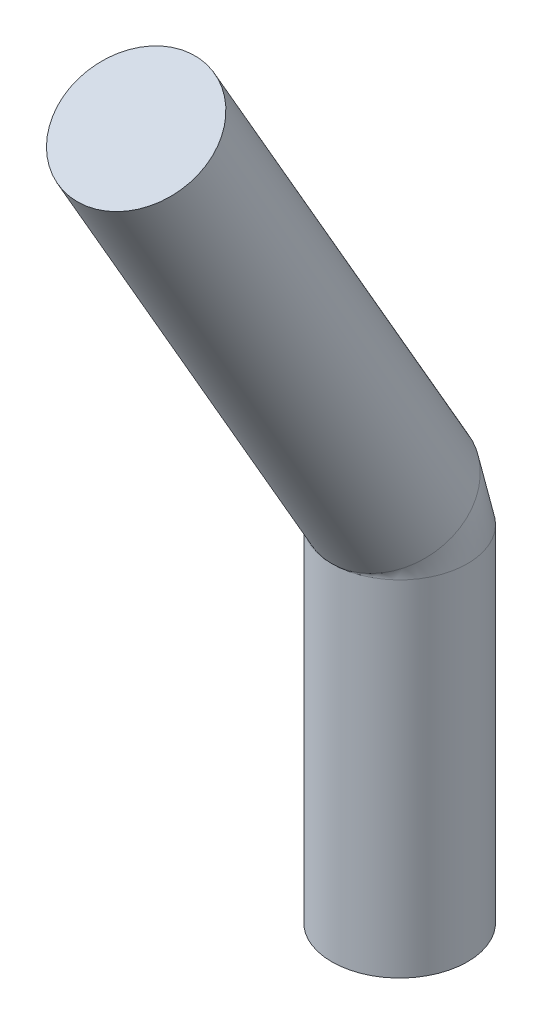
from build123d import *

# Parameters (mm, degrees)
SKETCH23_R          = 0.6
SKETCH25_R          = 0.6
BOSS_EXTRUDE2_DEPTH = 2.55


with BuildPart() as part:
    # Sweep4: sweep along a path in Sketch24
    with BuildLine(Plane(origin=(0, 0, 0), x_dir=(0, 0, -1), z_dir=(1, 0, 0))) as sweep4_path:
        Line((0, 0), (0, 0.5))
        ThreePointArc((0, 0.5), (-0.020444504, 0.655291427), (-0.080384758, 0.8))
        Line((-0.080384758, 0.8), (-2.330384758, 4.697114317))
    # Sketch23 → Sweep4 (sweep)
    with BuildSketch(Plane(origin=(0, 0, 0), x_dir=(1, 0, 0), z_dir=(0, 1, 0))):
        Circle(SKETCH23_R)
    sweep(path=sweep4_path.line)

    # Sketch25 → Boss-Extrude2 (add)
    with BuildSketch(Plane(origin=(0, 0, 0), x_dir=(-1, 0, 0), z_dir=(0, -1, 0))):
        Circle(SKETCH25_R)
    extrude(amount=BOSS_EXTRUDE2_DEPTH)


solid = part.part
